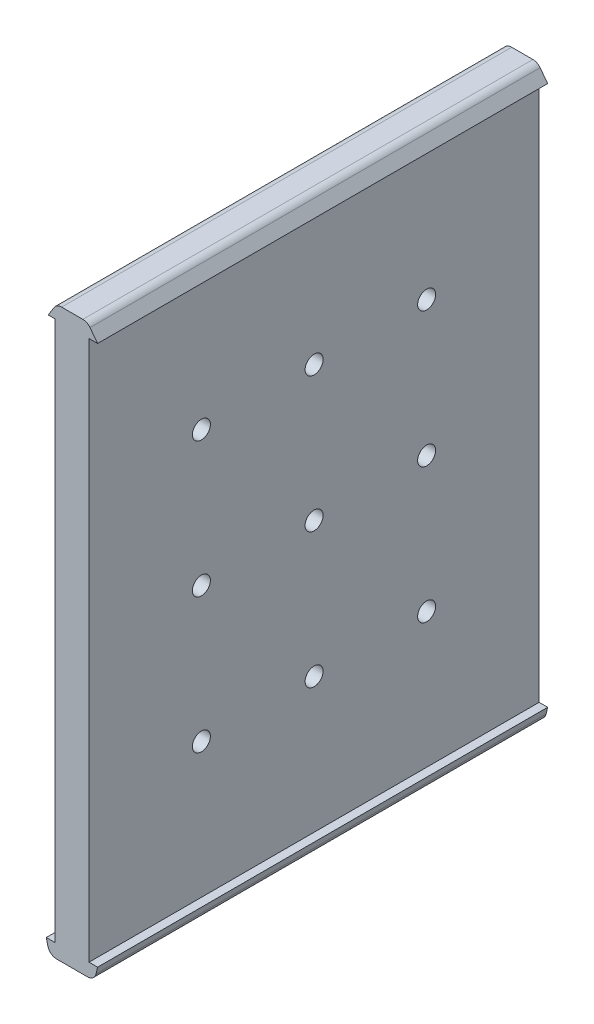
from build123d import *

# Parameters (mm, degrees)
RESSALTO_EXTRUS_O1_DEPTH   = 160
ESBO_O2_W                  = 7.6
ESBO_O2_H                  = 120
CORTE_EXTRUS_O1_DEPTH      = 30
CORTE_EXTRUS_O2_DEPTH      = 30
F_3DSKETCH3_R              = 2
CORTE_EXTRUS_O3_DEPTH      = 70
ESBO_O3_W                  = 45.015344868
ESBO_O3_H                  = 129.478543367
ESBO_O3_W_2                = 37.192593828
CORTE_EXTRUS_O4_DEPTH      = 41
CORTE_EXTRUS_O4_DEPTH_BACK = 22


with BuildPart() as part:
    # Esboço1 → Ressalto-extrusão1 (new body)
    with BuildSketch(Plane.XY):
        with BuildLine():
            Line((-3.8, 21.821375341), (-3.8, -98.178624659))
            Line((-3.8, -98.178624659), (-5.7, -98.178624659))
            Line((-5.7, -98.178624659), (-5.360626179, -99.63308389))
            ThreePointArc((-5.360626179, -99.63308389), (-4.656141559, -100.745296045), (-3.41294376, -101.178624659))
            Line((-3.41294376, -101.178624659), (3.41294376, -101.178624659))
            ThreePointArc((3.41294376, -101.178624659), (4.656141559, -100.745296045), (5.360626179, -99.63308389))
            Line((5.360626179, -99.63308389), (5.7, -98.178624659))
            Line((5.7, -98.178624659), (3.8, -98.178624659))
            Line((3.8, -98.178624659), (3.8, 21.821375341))
            Line((3.8, 21.821375341), (5.7, 21.821375341))
            Line((5.7, 21.821375341), (4.013268169, 24.033911877))
            ThreePointArc((4.013268169, 24.033911877), (3.310139149, 24.613730366), (2.422747768, 24.821375341))
            Line((2.422747768, 24.821375341), (-2.297792791, 24.821375341))
            ThreePointArc((-2.297792791, 24.821375341), (-3.27177376, 24.568189891), (-3.999156919, 23.872736414))
            Line((-3.999156919, 23.872736414), (-5.266799243, 21.821375341))
            Line((-5.266799243, 21.821375341), (-3.8, 21.821375341))
        make_face()
    extrude(amount=RESSALTO_EXTRUS_O1_DEPTH)

    # Esboço2 → Corte-extrusão1 (cut)
    with BuildSketch(Plane.XY):
        with Locations((0, -38.178624659)):
            Rectangle(ESBO_O2_W, ESBO_O2_H)
    extrude(amount=CORTE_EXTRUS_O1_DEPTH, mode=Mode.SUBTRACT)

    # 3DSketch2 → Corte-extrusão2 (cut)
    with BuildSketch(Plane(origin=(-3.8, 21.821375341, 160), x_dir=(0.0632066956560733, -0.9980004577274705, 0), z_dir=(0, 0, -1))):
        Polygon((0, 0), (0.480370887, -7.584803479), (120.240425814, 0), (119.760054927, 7.584803479), align=None)
    extrude(amount=CORTE_EXTRUS_O2_DEPTH, mode=Mode.SUBTRACT)

    # 3DSketch3 → Corte-extrusão3 (cut)
    with BuildSketch(Plane(origin=(3.8, -38.178624659, 80), x_dir=(0, 0.7676852805184269, 0.6408270516101394), z_dir=(1, 0, 0))):
        with Locations(Location((0, 0, 0), (0, 0, 140.146481665))):
            Circle(F_3DSKETCH3_R)
        with Locations(Location((23.030558416, -19.224811548, 0), (0, 0, 140.146481665))):
            Circle(F_3DSKETCH3_R)
        with Locations(Location((-23.030558416, 19.224811548, 0), (0, 0, 140.146481665))):
            Circle(F_3DSKETCH3_R)
        with Locations(Location((-39.051234706, 0.032679535, 0), (0, 0, 140.146481665))):
            Circle(F_3DSKETCH3_R)
        with Locations(Location((-16.02067629, -19.192132013, 0), (0, 0, 140.146481665))):
            Circle(F_3DSKETCH3_R)
        with Locations(Location((7.009882125, -38.416943561, 0), (0, 0, 140.146481665))):
            Circle(F_3DSKETCH3_R)
        with Locations(Location((-6.982602808, 38.449623097, 0), (0, 0, 140.146481665))):
            Circle(F_3DSKETCH3_R)
        with Locations(Location((16.047955607, 19.224811548, 0), (0, 0, 140.146481665))):
            Circle(F_3DSKETCH3_R)
        with Locations(Location((39.078514023, 0, 0), (0, 0, 140.146481665))):
            Circle(F_3DSKETCH3_R)
    extrude(amount=-CORTE_EXTRUS_O3_DEPTH, mode=Mode.SUBTRACT)

    # Esboço3 → Corte-extrusão4 (cut, two sides)
    with BuildSketch(Plane(origin=(0, 0, 0), x_dir=(0, 0, -1), z_dir=(1, 0, 0))) as corte_extrus_o4_sk:
        with Locations((-7.492327566, -39.917896343)):
            Rectangle(ESBO_O3_W, ESBO_O3_H)
        with Locations((-148.596296914, -39.917896343)):
            Rectangle(ESBO_O3_W_2, ESBO_O3_H)
    extrude(amount=CORTE_EXTRUS_O4_DEPTH, mode=Mode.SUBTRACT)
    extrude(corte_extrus_o4_sk.sketch, amount=-CORTE_EXTRUS_O4_DEPTH_BACK, mode=Mode.SUBTRACT)


solid = part.part
